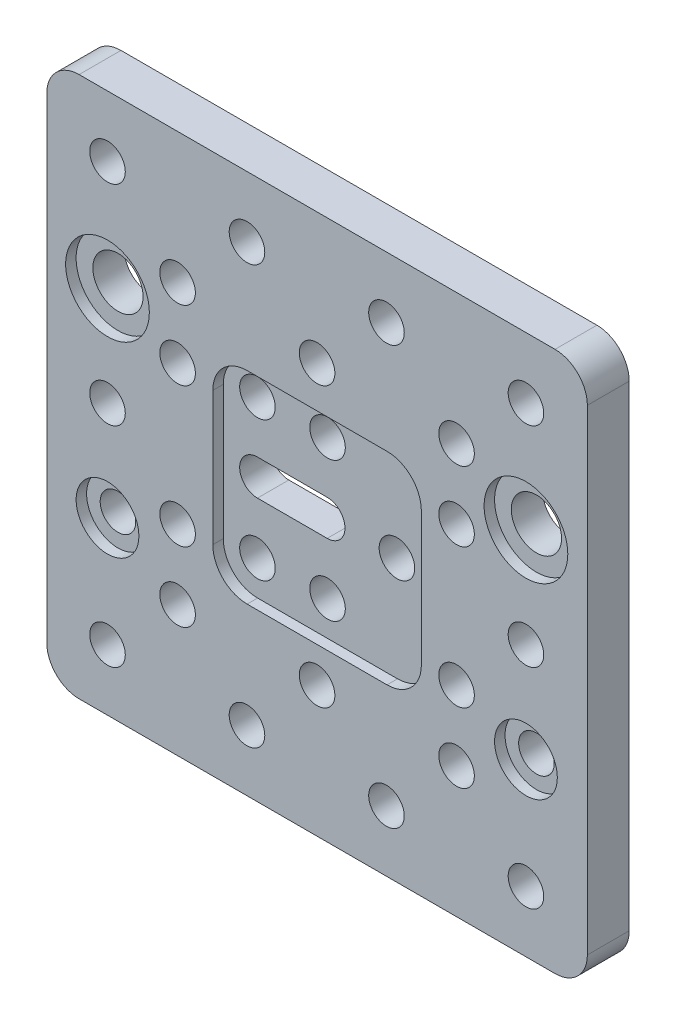
from build123d import *

# Parameters (mm, degrees)
SKETCH1_W           = 77.51
SKETCH1_H           = 77.519
SKETCH1_R           = 2.55
BOSS_EXTRUDE1_DEPTH = 6
CUT_EXTRUDE1_DEPTH  = 6
FILLET1_R           = 4.635
CUT_EXTRUDE2_DEPTH  = 1.5
SKETCH4_R           = 4.5
SKETCH4_R_2         = 6
CUT_EXTRUDE3_DEPTH  = 1.5
SKETCH5_R           = 3.6
CUT_EXTRUDE4_DEPTH  = 7


with BuildPart() as part:
    # Sketch1 → Boss-Extrude1 (new body)
    with BuildSketch(Plane.XY):
        Rectangle(SKETCH1_W, SKETCH1_H)
        with Locations((-30.05, 30.0005)):
            Circle(SKETCH1_R, mode=Mode.SUBTRACT)
        with Locations((-10.05, 30.0005)):
            Circle(SKETCH1_R, mode=Mode.SUBTRACT)
        with Locations((-10.05, -29.9995)):
            Circle(SKETCH1_R, mode=Mode.SUBTRACT)
        with Locations((0, 20)):
            Circle(SKETCH1_R, mode=Mode.SUBTRACT)
        with Locations((0, 10)):
            Circle(SKETCH1_R, mode=Mode.SUBTRACT)
        with Locations((-10.05, 10)):
            Circle(SKETCH1_R, mode=Mode.SUBTRACT)
        with Locations((9.95, 30.0005)):
            Circle(SKETCH1_R, mode=Mode.SUBTRACT)
        with Locations((9.95, -29.9995)):
            Circle(SKETCH1_R, mode=Mode.SUBTRACT)
        with Locations((-10.05, -10)):
            Circle(SKETCH1_R, mode=Mode.SUBTRACT)
        with Locations((9.95, 0.0005)):
            Circle(SKETCH1_R, mode=Mode.SUBTRACT)
        with Locations((-30.05, -29.9995)):
            Circle(SKETCH1_R, mode=Mode.SUBTRACT)
        with Locations((-30.05, -14.2495)):
            Circle(SKETCH1_R, mode=Mode.SUBTRACT)
        with Locations((-30.05, 0.0005)):
            Circle(SKETCH1_R, mode=Mode.SUBTRACT)
        with Locations((-30.05, 14.2505)):
            Circle(SKETCH1_R, mode=Mode.SUBTRACT)
        with Locations((0, -10)):
            Circle(SKETCH1_R, mode=Mode.SUBTRACT)
        with Locations((29.95, 30.0005)):
            Circle(SKETCH1_R, mode=Mode.SUBTRACT)
        with Locations((29.95, -29.9995)):
            Circle(SKETCH1_R, mode=Mode.SUBTRACT)
        with Locations((29.95, -14.2495)):
            Circle(SKETCH1_R, mode=Mode.SUBTRACT)
        with Locations((29.95, 0.0005)):
            Circle(SKETCH1_R, mode=Mode.SUBTRACT)
        with Locations((29.95, 14.2505)):
            Circle(SKETCH1_R, mode=Mode.SUBTRACT)
        with Locations((0, -20)):
            Circle(SKETCH1_R, mode=Mode.SUBTRACT)
        with Locations((20, 20)):
            Circle(SKETCH1_R, mode=Mode.SUBTRACT)
        with Locations((20, 10)):
            Circle(SKETCH1_R, mode=Mode.SUBTRACT)
        with Locations((20, -10)):
            Circle(SKETCH1_R, mode=Mode.SUBTRACT)
        with Locations((20, -20)):
            Circle(SKETCH1_R, mode=Mode.SUBTRACT)
        with Locations((-20, 20)):
            Circle(SKETCH1_R, mode=Mode.SUBTRACT)
        with Locations((-20, 10)):
            Circle(SKETCH1_R, mode=Mode.SUBTRACT)
        with Locations((-20, -10)):
            Circle(SKETCH1_R, mode=Mode.SUBTRACT)
        with Locations((-20, -20)):
            Circle(SKETCH1_R, mode=Mode.SUBTRACT)
    extrude(amount=BOSS_EXTRUDE1_DEPTH)

    # Sketch2 → Cut-Extrude1 (cut)
    with BuildSketch(Plane.XY.offset(6)):
        with BuildLine():
            Line((-10.049999987, 2.55), (-0.049999987, 2.55))
            ThreePointArc((-0.049999987, 2.55), (2.500000013, 0), (-0.049999987, -2.55))
            Line((-0.049999987, -2.55), (-10.049999987, -2.55))
            ThreePointArc((-10.049999987, -2.55), (-12.599999987, 0), (-10.049999987, 2.55))
        make_face()
    extrude(amount=-CUT_EXTRUDE1_DEPTH, mode=Mode.SUBTRACT)

    # Fillet1
    fillet1_edges = [part.edges().sort_by_distance(p)[0] for p in [
        (-38.755, 38.7595, 3),
        (38.755, 38.7595, 3),
        (38.755, -38.7595, 3),
        (-38.755, -38.7595, 3),
    ]]
    fillet(fillet1_edges, radius=FILLET1_R)

    # Sketch3 → Cut-Extrude2 (cut)
    with BuildSketch(Plane.XY.offset(6)):
        with BuildLine():
            Line((-10.03, 14.05), (10.03, 14.05))
            ThreePointArc((10.03, 14.05), (13.50967247, 12.60867247), (14.951, 9.129))
            Line((14.951, 9.129), (14.951, -10.029))
            ThreePointArc((14.951, -10.029), (13.50967247, -13.50867247), (10.03, -14.95))
            Line((10.03, -14.95), (-10.03, -14.95))
            ThreePointArc((-10.03, -14.95), (-13.50967247, -13.50867247), (-14.951, -10.029))
            Line((-14.951, -10.029), (-14.951, 9.129))
            ThreePointArc((-14.951, 9.129), (-13.50967247, 12.60867247), (-10.03, 14.05))
        make_face()
    extrude(amount=-CUT_EXTRUDE2_DEPTH, mode=Mode.SUBTRACT)

    # Sketch4 → Cut-Extrude3 (cut)
    with BuildSketch(Plane.XY.offset(6)):
        with Locations((-30.05, -14.2495)):
            Circle(SKETCH4_R)
        with Locations((29.95, -14.2495)):
            Circle(SKETCH4_R)
        with Locations((-30.05, 14.2505)):
            Circle(SKETCH4_R_2)
        with Locations((29.95, 14.2505)):
            Circle(SKETCH4_R_2)
    extrude(amount=-CUT_EXTRUDE3_DEPTH, mode=Mode.SUBTRACT)

    # Sketch5 → Cut-Extrude4 (cut, through all)
    with BuildSketch(Plane.XY.offset(6)):
        with Locations((-30.05, 14.2505)):
            Circle(SKETCH5_R)
        with Locations((29.95, 14.2505)):
            Circle(SKETCH5_R)
    extrude(amount=-CUT_EXTRUDE4_DEPTH, mode=Mode.SUBTRACT)


solid = part.part
